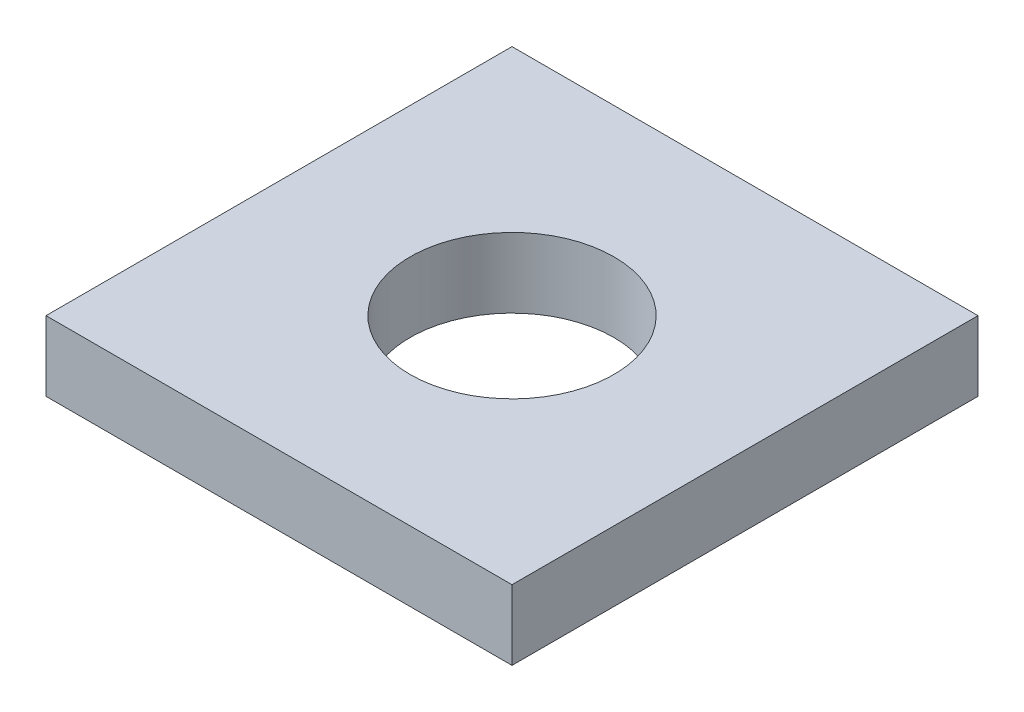
from build123d import *

# Parameters (mm, degrees)
SKETCH1_W           = 40
SKETCH1_H           = 40
SKETCH1_R           = 8.75
BOSS_EXTRUDE1_DEPTH = 6


with BuildPart() as part:
    # Sketch1 → Boss-Extrude1 (new body)
    with BuildSketch(Plane(origin=(0, 0, 0), x_dir=(1, 0, 0), z_dir=(0, 1, 0))):
        Rectangle(SKETCH1_W, SKETCH1_H)
        Circle(SKETCH1_R, mode=Mode.SUBTRACT)
    extrude(amount=BOSS_EXTRUDE1_DEPTH)


solid = part.part
